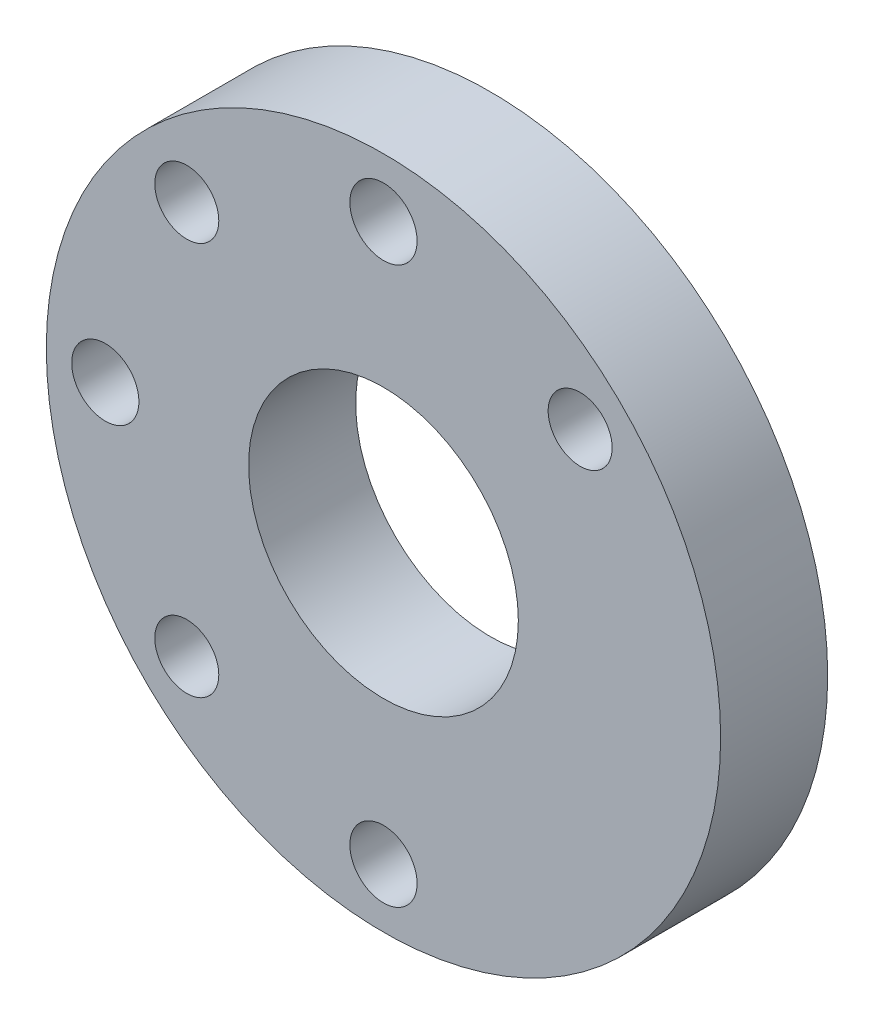
from build123d import *

# Parameters (mm, degrees)
SKETCH1_R           = 20
SKETCH1_R_2         = 8
SKETCH1_R_3         = 1.9939
SKETCH1_R_4         = 1.89865
BOSS_EXTRUDE1_DEPTH = 6.35


with BuildPart() as part:
    # Sketch1 → Boss-Extrude1 (new body)
    with BuildSketch(Plane.XY):
        Circle(SKETCH1_R)
        Circle(SKETCH1_R_2, mode=Mode.SUBTRACT)
        with Locations((0, 16.5)):
            Circle(SKETCH1_R_3, mode=Mode.SUBTRACT)
        with Locations((11.66726189, 11.66726189)):
            Circle(SKETCH1_R_4, mode=Mode.SUBTRACT)
        with Locations((0, -16.5)):
            Circle(SKETCH1_R_3, mode=Mode.SUBTRACT)
        with Locations((-11.66726189, -11.66726189)):
            Circle(SKETCH1_R_4, mode=Mode.SUBTRACT)
        with Locations((-16.5, 0)):
            Circle(SKETCH1_R_3, mode=Mode.SUBTRACT)
        with Locations((-11.66726189, 11.66726189)):
            Circle(SKETCH1_R_4, mode=Mode.SUBTRACT)
    extrude(amount=BOSS_EXTRUDE1_DEPTH)


solid = part.part
